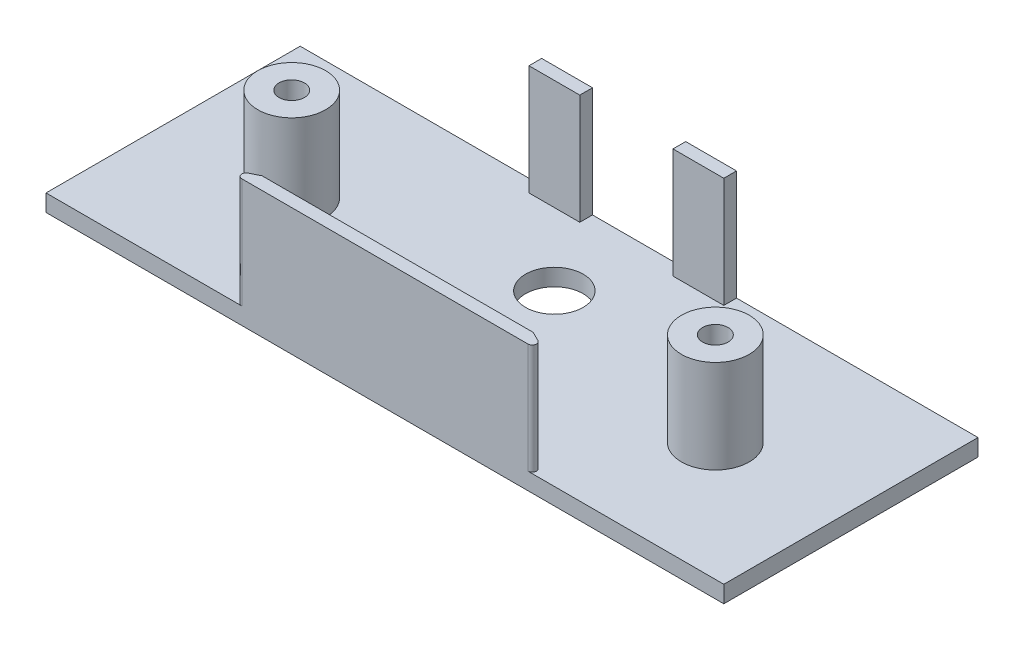
from build123d import *

# Parameters (mm, degrees)
SKETCH2_W           = 80
SKETCH2_H           = 30
SKETCH2_R           = 1.5
SKETCH2_R_2         = 3.4
BOSS_EXTRUDE1_DEPTH = 2
SKETCH3_W           = 6
SKETCH3_H           = 1.5
BOSS_EXTRUDE2_DEPTH = 13
SKETCH9_R           = 4
SKETCH9_R_2         = 1.5
BOSS_EXTRUDE4_DEPTH = 11
FILLET1_R           = 0.5
CHAMFER1_SIZE       = 2


with BuildPart() as part:
    # Sketch2 → Boss-Extrude1 (new body)
    with BuildSketch(Plane(origin=(0, 0, 0), x_dir=(1, 0, 0), z_dir=(0, 1, 0))):
        with Locations((25, 1)):
            Rectangle(SKETCH2_W, SKETCH2_H)
        with Locations(Location((0, 0, 0), (0, 0, 270))):  # turned: the seam where the file's is
            Circle(SKETCH2_R, mode=Mode.SUBTRACT)
        with Locations(Location((50, 0, 0), (0, 0, 270))):  # turned: the seam where the file's is
            Circle(SKETCH2_R, mode=Mode.SUBTRACT)
        with Locations(Location((25, 6, 0), (0, 0, 270))):  # turned: the seam where the file's is
            Circle(SKETCH2_R_2, mode=Mode.SUBTRACT)
    extrude(amount=BOSS_EXTRUDE1_DEPTH)

    # Sketch3 → Boss-Extrude2 (add)
    with BuildSketch(Plane(origin=(0, 2, 0), x_dir=(1, 0, 0), z_dir=(0, 1, 0))):
        Polygon((6, -14), (44, -14), (41, -12.5), (9, -12.5), align=None)
        with Locations((16.5, 15.25)):
            Rectangle(SKETCH3_W, SKETCH3_H)
        with Locations((33.5, 15.25)):
            Rectangle(SKETCH3_W, SKETCH3_H)
    extrude(amount=BOSS_EXTRUDE2_DEPTH)

    # Sketch9 → Boss-Extrude4 (add)
    with BuildSketch(Plane(origin=(0, 2, 0), x_dir=(1, 0, 0), z_dir=(0, 1, 0))):
        with Locations(Location((50, 0, 0), (0, 0, 90))):  # turned: the seam where the file's is
            Circle(SKETCH9_R)
        with Locations(Location((50, 0, 0), (0, 0, 270))):  # turned: the seam where the file's is
            Circle(SKETCH9_R_2, mode=Mode.SUBTRACT)
        with Locations(Location((0, 0, 0), (0, 0, 90))):  # turned: the seam where the file's is
            Circle(SKETCH9_R)
        with Locations(Location((0, 0, 0), (0, 0, 270))):  # turned: the seam where the file's is
            Circle(SKETCH9_R_2, mode=Mode.SUBTRACT)
    extrude(amount=BOSS_EXTRUDE4_DEPTH)

    # Fillet1
    fillet1_edges = [part.edges().sort_by_distance(p)[0] for p in [
        (6, 8.5, 14),
        (44, 8.5, 14),
    ]]
    fillet(fillet1_edges, radius=FILLET1_R)

    # Chamfer1
    chamfer1_edges = [part.edges().sort_by_distance(p)[0] for p in [
        (25, 2, 12.5),
    ]]
    chamfer(chamfer1_edges, length=CHAMFER1_SIZE)


solid = part.part
